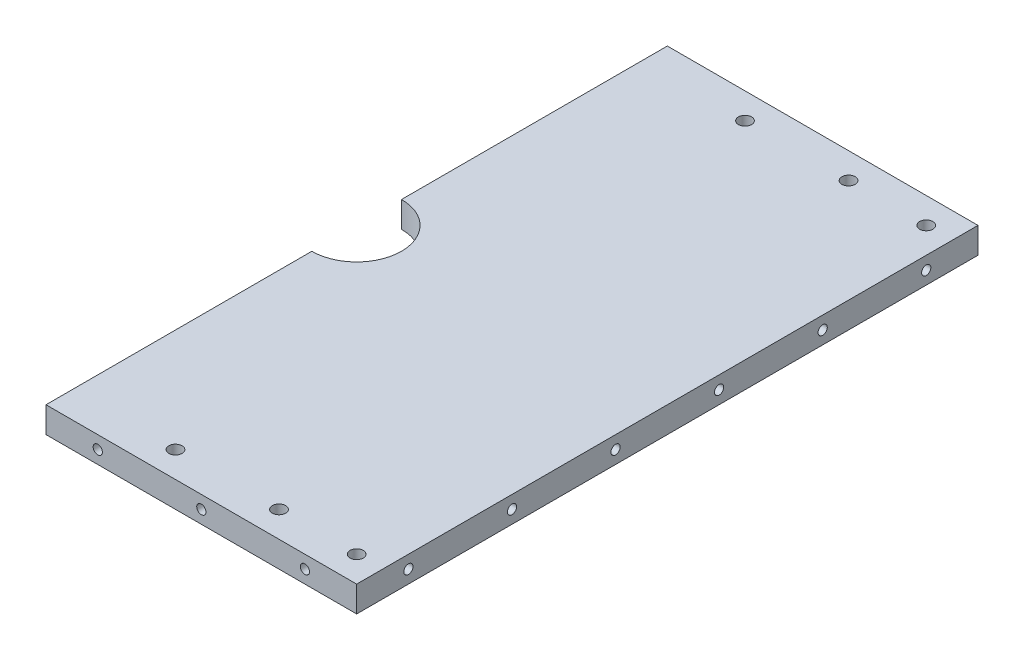
from build123d import *

# Parameters (mm, degrees)
SKETCH1_R           = 1.63195
BOSS_EXTRUDE1_DEPTH = 6.35
LPATTERN1_COUNT     = 6
LPATTERN1_PITCH     = 25.4
LPATTERN2_COUNT     = 3
LPATTERN2_PITCH     = 25.4


with BuildPart() as part:
    # Sketch1 → Boss-Extrude1 (new body)
    with BuildSketch(Plane(origin=(0, 0, 0), x_dir=(1, 0, 0), z_dir=(0, 1, 0))):
        with BuildLine():
            Line((0, -11), (0, -76.2))
            Line((0, -76.2), (76.2, -76.2))
            Line((76.2, -76.2), (76.2, 76.2))
            Line((76.2, 76.2), (0, 76.2))
            Line((0, 76.2), (0, 11))
            ThreePointArc((0, 11), (11, 0), (0, -11))
        make_face()
        with Locations((69.85, 69.85)):
            Circle(SKETCH1_R, mode=Mode.SUBTRACT)
        with Locations((69.85, -69.85)):
            Circle(SKETCH1_R, mode=Mode.SUBTRACT)
        with Locations((50.8, 69.85)):
            Circle(SKETCH1_R, mode=Mode.SUBTRACT)
        with Locations((25.4, 69.85)):
            Circle(SKETCH1_R, mode=Mode.SUBTRACT)
        with Locations((50.8, -69.85)):
            Circle(SKETCH1_R, mode=Mode.SUBTRACT)
        with Locations((25.4, -69.85)):
            Circle(SKETCH1_R, mode=Mode.SUBTRACT)
    extrude(amount=BOSS_EXTRUDE1_DEPTH)

    # Sketch2 → #4-40 Tapped Hole1 (revolve, cut)
    with BuildSketch(Plane(origin=(76.2, 3.175, 63.5), x_dir=(0, 0, -1), z_dir=(0, 1, 0))):
        Polygon((0, 0), (0, 8.279152758), (1.1303, 7.6), (1.1303, 0), align=None)
    f_4_40_tapped_hole1 = revolve(axis=Axis((82.55, 3.175, 63.5), (-1, 0, 0)), mode=Mode.SUBTRACT)

    # LPattern1: #4-40 Tapped Hole1 ×6
    with Locations(*[(0, 0, -i * LPATTERN1_PITCH) for i in range(1, LPATTERN1_COUNT)]):
        add(f_4_40_tapped_hole1, mode=Mode.SUBTRACT)

    # Sketch3 → #4-40 Tapped Hole2 (revolve, cut)
    with BuildSketch(Plane(origin=(63.5, 3.175, 76.2), x_dir=(0, -1, 0), z_dir=(1, 0, 0))):
        Polygon((0, 0), (0, 8.279152758), (1.1303, 7.6), (1.1303, 0), align=None)
    f_4_40_tapped_hole2 = revolve(axis=Axis((63.5, 3.175, 82.55), (0, 0, -1)), mode=Mode.SUBTRACT)

    # LPattern2: #4-40 Tapped Hole2 ×3
    with Locations(*[(-i * LPATTERN2_PITCH, 0, 0) for i in range(1, LPATTERN2_COUNT)]):
        add(f_4_40_tapped_hole2, mode=Mode.SUBTRACT)

    # Mirror1: #4-40 Tapped Hole2 across plane
    add(f_4_40_tapped_hole2.mirror(Plane.XY), mode=Mode.SUBTRACT)

    # Mirror1 copy 1 sketch → Mirror1 copy 1 (revolve, cut)
    with BuildSketch(Plane(origin=(38.1, 3.175, -76.2), x_dir=(0, -1, 0), z_dir=(1, 0, 0))):
        Polygon((0, 0), (0, -8.279152758), (1.1303, -7.6), (1.1303, 0), align=None)
    revolve(axis=Axis((38.1, 3.175, -82.55), (0, 0, -1)), mode=Mode.SUBTRACT)

    # Mirror1 copy 2 sketch → Mirror1 copy 2 (revolve, cut)
    with BuildSketch(Plane(origin=(12.7, 3.175, -76.2), x_dir=(0, -1, 0), z_dir=(1, 0, 0))):
        Polygon((0, 0), (0, -8.279152758), (1.1303, -7.6), (1.1303, 0), align=None)
    revolve(axis=Axis((12.7, 3.175, -82.55), (0, 0, -1)), mode=Mode.SUBTRACT)


solid = part.part
